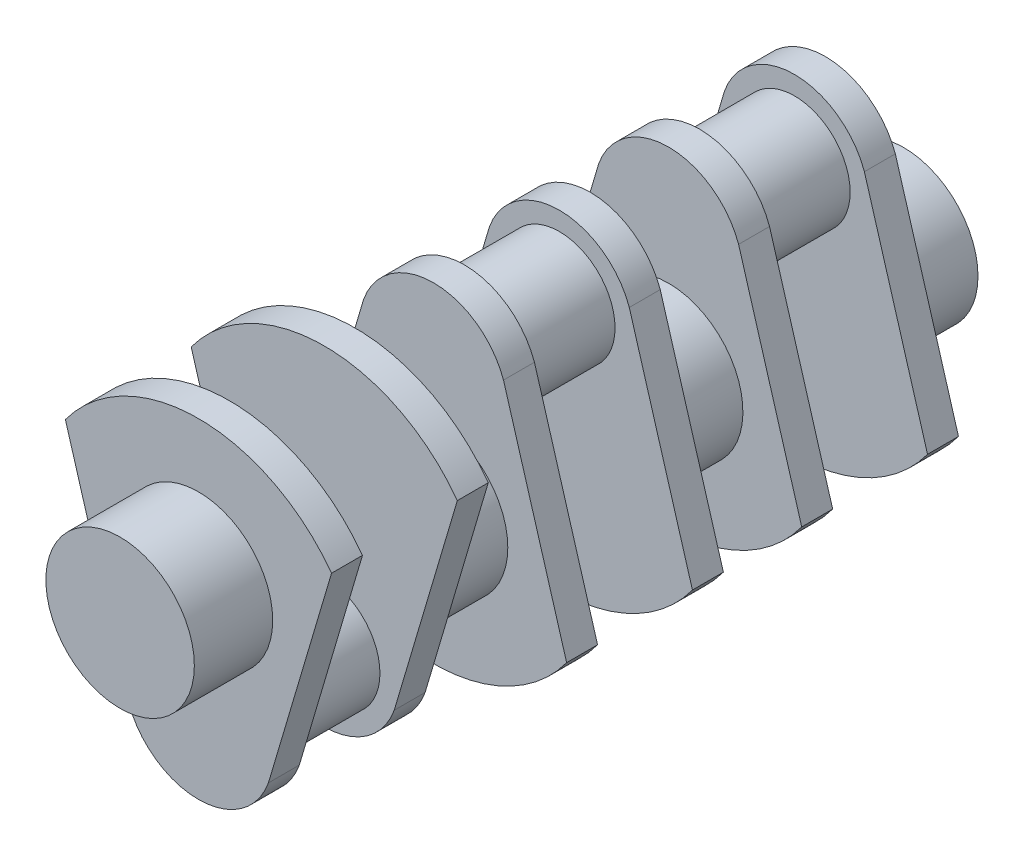
from build123d import *

# Parameters (mm, degrees)
BOSS_EXTRUDE1_DEPTH   = 381
SKETCH3_R             = 685.8
BOSS_EXTRUDE2_DEPTH   = 1168.4
SKETCH4_R             = 914.4
BOSS_EXTRUDE5_DEPTH   = 965.2
BODY_MOVE_COPY6_ANGLE = 180
SKETCH7_R             = 914.4
BOSS_EXTRUDE7_DEPTH   = 965.2


with BuildPart() as part:
    # Sketch2 → Boss-Extrude1 (new body)
    with BuildSketch(Plane.XY):
        with BuildLine():
            ThreePointArc((1639.073881445, 865.438888575), (0, 1696.413988265), (-1639.073881445, 865.438888575))
            Line((-1639.073881445, 865.438888575), (-889.551566195, -1664.906041679))
            ThreePointArc((-889.551566195, -1664.906041679), (-106.586602983, -545.019366199), (914.4, -1453.186011735))
            ThreePointArc((914.4, -1453.186011735), (908.166645536, -1559.772614718), (889.551566195, -1664.906041679))
            Line((889.551566195, -1664.906041679), (1639.073881445, 865.438888575))
        make_face()
        with BuildLine():
            ThreePointArc((914.4, -1453.186011735), (-106.586602983, -545.019366199), (-889.551566195, -1664.906041679))
            Line((-889.551566195, -1664.906041679), (-861.35171004, -1760.107160586))
            ThreePointArc((-861.35171004, -1760.107160586), (0, -2367.586011735), (861.35171004, -1760.107160586))
            Line((861.35171004, -1760.107160586), (889.551566195, -1664.906041679))
            ThreePointArc((889.551566195, -1664.906041679), (908.166645536, -1559.772614718), (914.4, -1453.186011735))
        make_face()
    extrude(amount=BOSS_EXTRUDE1_DEPTH)

    # Sketch3 → Boss-Extrude2 (add)
    with BuildSketch(Plane(origin=(0, 0, 0), x_dir=(-1, 0, 0), z_dir=(0, 0, -1))):
        with Locations((0, -1453.186011735)):
            Circle(SKETCH3_R)
    extrude(amount=BOSS_EXTRUDE2_DEPTH)

    # Mirror9: part across plane


with BuildPart() as part_1:
    add(part.part)
    add(part.part.mirror(Plane(origin=(0, 0, -584.2), x_dir=(1, 0, 0), z_dir=(0, 0, -1))))

    # Sketch4 → Boss-Extrude5 (add)
    with BuildSketch(Plane.XY.offset(381)):
        Circle(SKETCH4_R)
    extrude(amount=BOSS_EXTRUDE5_DEPTH)


with BuildPart() as body_2:
    # Mirror14: mirrored copy
    add(part_1.part.mirror(Plane(origin=(0, 0, -2032), x_dir=(1, 0, 0), z_dir=(0, 0, -1))))


with BuildPart() as body_2_1:
    # Body-Move/Copy6: moved
    add(body_2.part.rotate(Axis((0, -335.586011735, -3962.4), (1, 0, 0)), BODY_MOVE_COPY6_ANGLE))


with BuildPart() as body_2_2:
    # Body-Move/Copy7: moved
    add(body_2_1.part.moved(Location((0, 0, 965.2))))


with BuildPart() as body_3:
    # Mirror16: mirrored copy
    add(body_2_2.part.mirror(Plane(origin=(0, 0, -4927.6), x_dir=(1, 0, 0), z_dir=(0, 0, -1))))


with BuildPart() as body_2_3:
    add(body_2_2.part)

    add(body_3.part)  # Boss-Extrude7 merges body 3
    # Sketch7 → Boss-Extrude7 (add)
    with BuildSketch(Plane(origin=(0, 0, -4445), x_dir=(-1, 0, 0), z_dir=(0, 0, -1))):
        with Locations((0, -671.17202347)):
            Circle(SKETCH7_R)
    extrude(amount=BOSS_EXTRUDE7_DEPTH)


solid = Compound([part_1.part, body_2_3.part])
